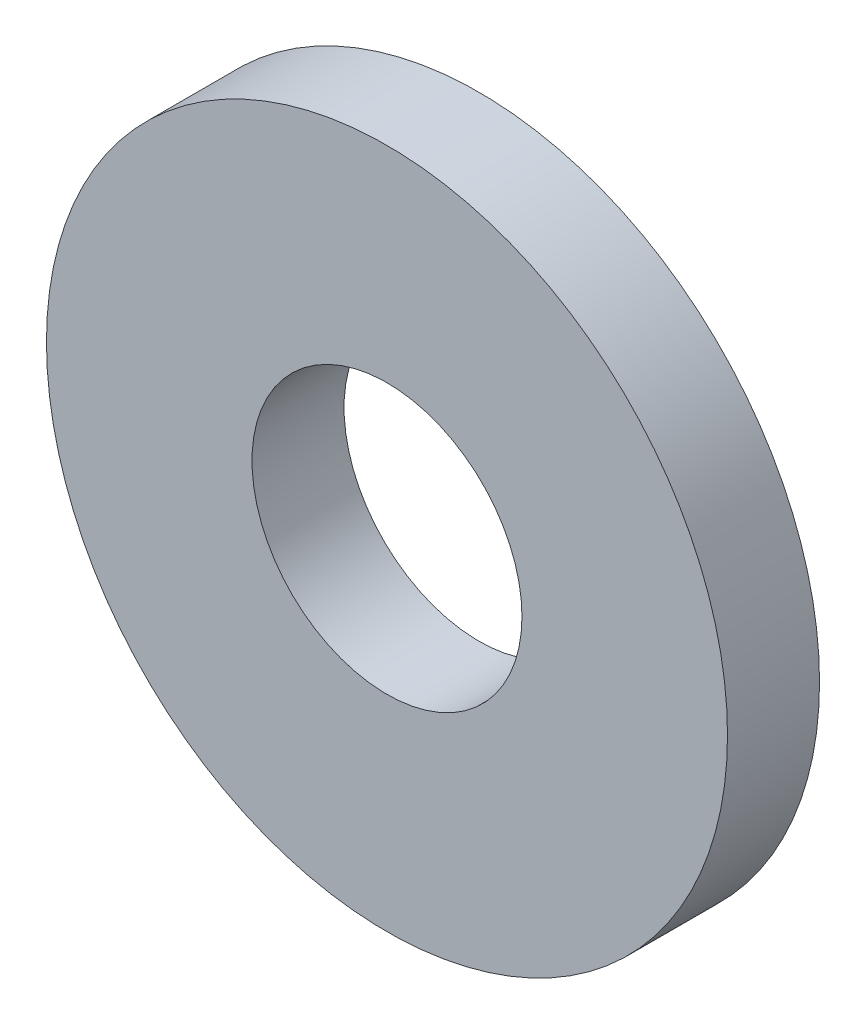
from build123d import *

# Parameters (mm, degrees)
SKETCH1_R           = 5.55
SKETCH1_R_2         = 2.2
BOSS_EXTRUDE1_DEPTH = 1.5


with BuildPart() as part:
    # Sketch1 → Boss-Extrude1 (new body)
    with BuildSketch(Plane.XY):
        Circle(SKETCH1_R)
        Circle(SKETCH1_R_2, mode=Mode.SUBTRACT)
    extrude(amount=BOSS_EXTRUDE1_DEPTH)


solid = part.part
